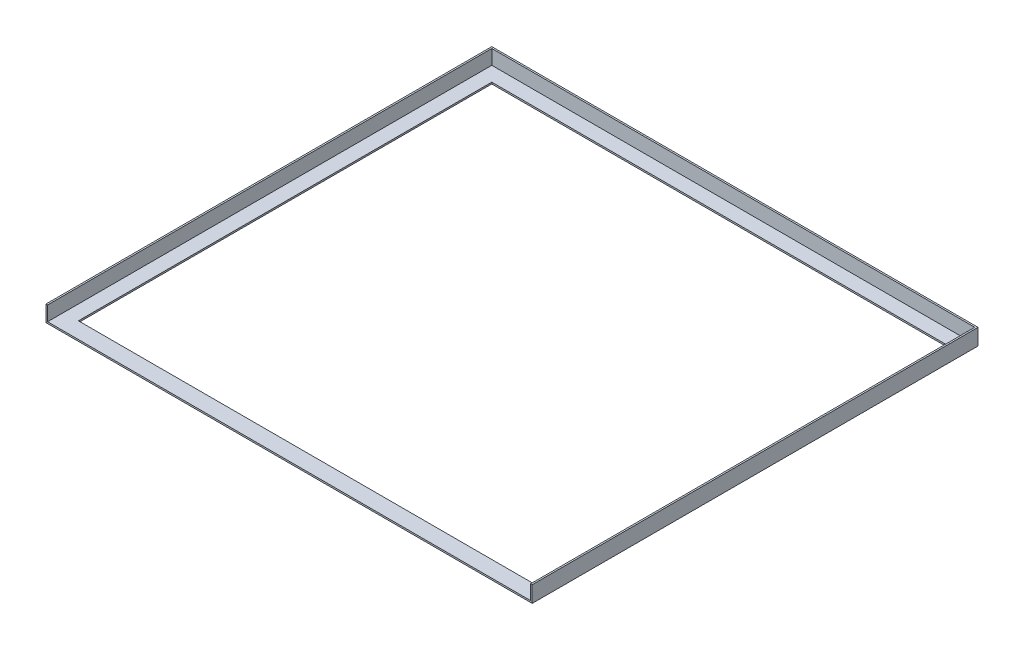
from build123d import *

# Parameters (mm, degrees)
SKETCH1_W           = 600
SKETCH1_H           = 20
BOSS_EXTRUDE1_DEPTH = 550.1
CUT_EXTRUDE1_DEPTH  = 18
CUT_EXTRUDE2_DEPTH  = 2
SKETCH2_W           = 596
SKETCH2_H           = 18
CUT_EXTRUDE3_DEPTH  = 2


with BuildPart() as part:
    # Sketch1 → Boss-Extrude1 (new body)
    with BuildSketch(Plane.XY):
        with Locations((221.099899989, 5.665003505)):
            Rectangle(SKETCH1_W, SKETCH1_H)
    extrude(amount=-BOSS_EXTRUDE1_DEPTH)

    # 3DSketch1 → Cut-Extrude1 (cut)
    with BuildSketch(Plane(origin=(519.099899989, 15.665003505, -548.1), x_dir=(-0.7372979045405654, 0, 0.6755677611906087), z_dir=(0, 1, 0))):
        Polygon((0, 0), (439.429551106, -402.63838567), (808.357105492, 0), (368.927554386, 402.63838567), align=None)
    extrude(amount=-CUT_EXTRUDE1_DEPTH, mode=Mode.SUBTRACT)

    # 3DSketch2 → Cut-Extrude2 (cut)
    with BuildSketch(Plane(origin=(-58.900100011, -2.334996495, -530.1), x_dir=(0.7392766587492063, 0, 0.6734018279070896), z_dir=(0, 1, 0))):
        Polygon((0, 0), (413.9949289, 377.105023628), (757.497201315, 0), (343.502272415, -377.105023628), align=None)
    extrude(amount=-CUT_EXTRUDE2_DEPTH, mode=Mode.SUBTRACT)

    # Sketch2 → Cut-Extrude3 (cut)
    with BuildSketch(Plane(origin=(0, 0, -2), x_dir=(-1, 0, 0), z_dir=(0, 0, -1))):
        with Locations((-221.099899989, 6.665003505)):
            Rectangle(SKETCH2_W, SKETCH2_H)
    extrude(amount=-CUT_EXTRUDE3_DEPTH, mode=Mode.SUBTRACT)


solid = part.part
